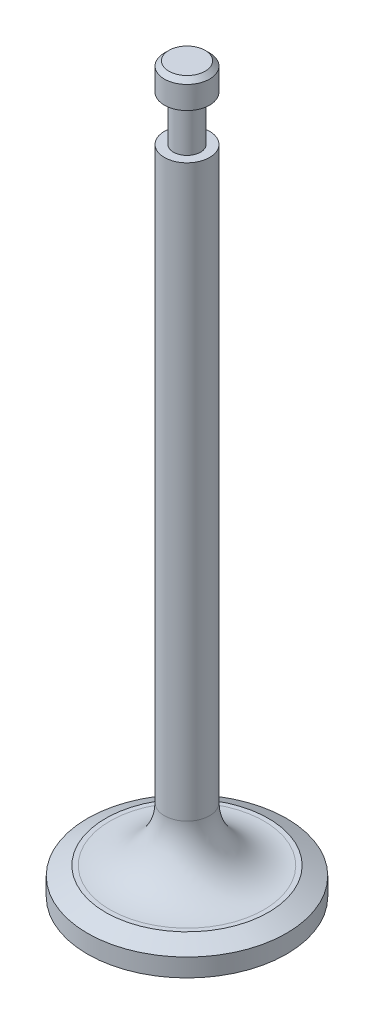
from build123d import *

# Parameters (mm, degrees)
FILLET1_R      = 6
CHAMFER1_SIZE  = 0.5
CHAMFER2_SIZE  = 2
CHAMFER2_SIZE2 = 1


with BuildPart() as part:
    # Sketch1 → Revolve1 (revolve)
    with BuildSketch(Plane.XY):
        Polygon((0, 0), (0, 80), (2.5, 80), (2.5, 77), (1.5, 77), (1.5, 72), (2.5, 72), (2.5, 3), (11, 3), (11, 0), align=None)
    revolve(axis=Axis((0, 0, 0), (0, 1, 0)))

    # Fillet1
    fillet1_edges = [part.edges().sort_by_distance(p)[0] for p in [
        (-2.5, 3, 0),
    ]]
    fillet(fillet1_edges, radius=FILLET1_R)

    # Chamfer1
    chamfer1_edges = [part.edges().sort_by_distance(p)[0] for p in [
        (-2.5, 80, 0),
    ]]
    chamfer(chamfer1_edges, length=CHAMFER1_SIZE)

    # Chamfer2
    chamfer2_edges = [part.edges().sort_by_distance(p)[0] for p in [
        (-11, 3, 0),
    ]]
    chamfer2_side = [part.faces().sort_by_distance(p)[0] for p in [
        (-8.811126984, 3, 0),
    ]]
    chamfer(chamfer2_edges, length=CHAMFER2_SIZE, length2=CHAMFER2_SIZE2, reference=chamfer2_side[0])


solid = part.part
